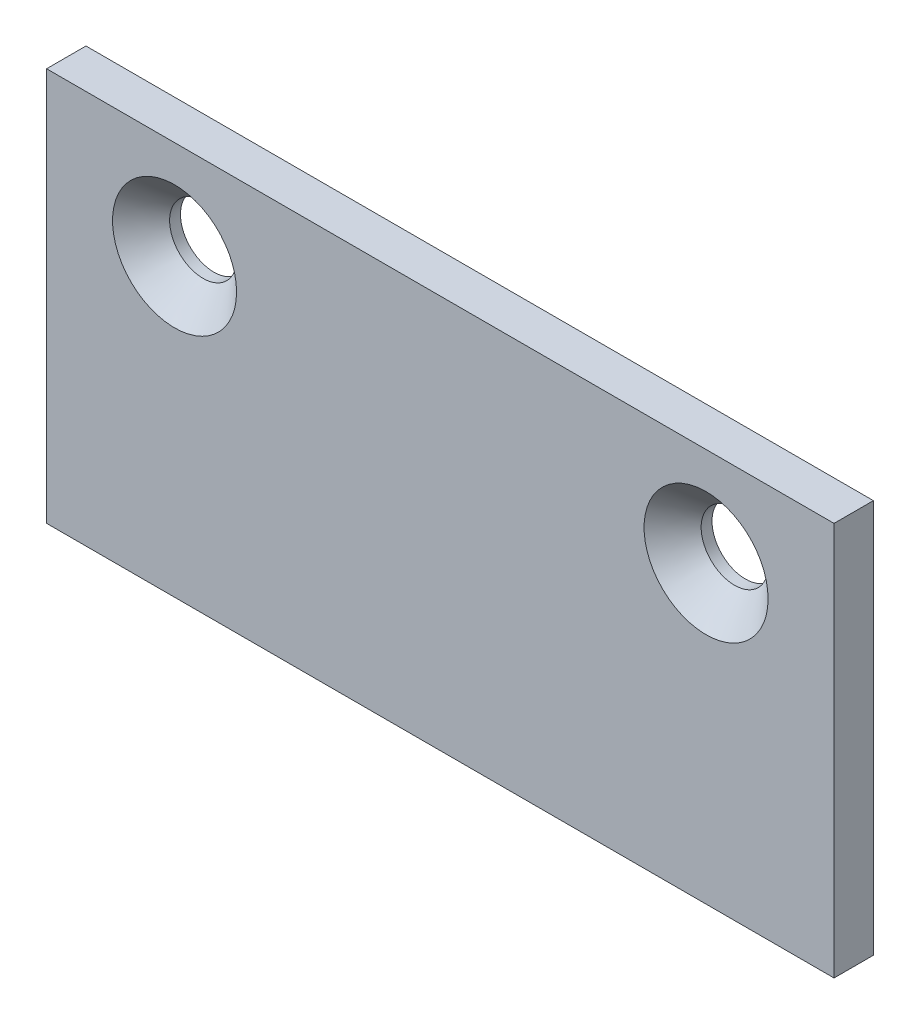
from build123d import *

# Parameters (mm, degrees)
SKETCH_1_W                  = 40
SKETCH_1_H                  = 20
EXTRUDE_1_DEPTH             = 2
HOLE_WIZARD_M3_1_AT_2_COUNT = 2
HOLE_WIZARD_M3_1_AT_2_PITCH = 27


with BuildPart() as part:
    # 草圖1 → 填料-伸長1 (new body)
    with BuildSketch(Plane.XY):
        Rectangle(SKETCH_1_W, SKETCH_1_H)
    extrude(amount=EXTRUDE_1_DEPTH)

    # 草圖2 → M3 平錐坑頭螺釘的錐孔1 (revolve, cut)
    with BuildSketch(Plane(origin=(-13.5, 5, 2), x_dir=(0, -1, 0), z_dir=(1, 0, 0))):
        Polygon((0, 0), (0, 2), (1.7, 2), (1.7, 1.45), (3.15, 0), align=None)
    hole_wizard_m3_1 = revolve(axis=Axis((-13.5, 5, 8.35), (0, 0, -1)), mode=Mode.SUBTRACT)

    # M3 平錐坑頭螺釘的錐孔1 at 2: M3 平錐坑頭螺釘的錐孔1 ×2
    with Locations(*[(i * HOLE_WIZARD_M3_1_AT_2_PITCH, 0, 0) for i in range(1, HOLE_WIZARD_M3_1_AT_2_COUNT)]):
        add(hole_wizard_m3_1, mode=Mode.SUBTRACT)


solid = part.part
